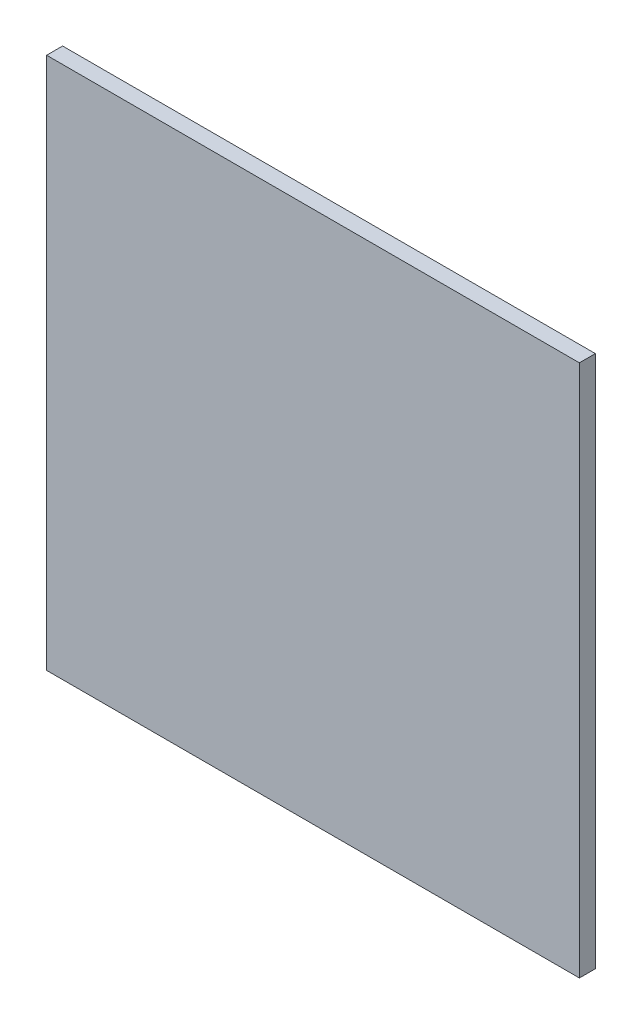
from build123d import *

# Parameters (mm, degrees)
BOSS_EXTRUDE1_DEPTH = 6


with BuildPart() as part:
    # Sketch1 → Boss-Extrude1 (new body)
    with BuildSketch(Plane.XY):
        Polygon((87.096774194, 78.225806452), (87.096774194, -21.774193548), (87.096774194, -121.774193548), (-112.903225806, -121.774193548), (-112.903225806, 78.225806452), align=None)
    extrude(amount=BOSS_EXTRUDE1_DEPTH)


solid = part.part
